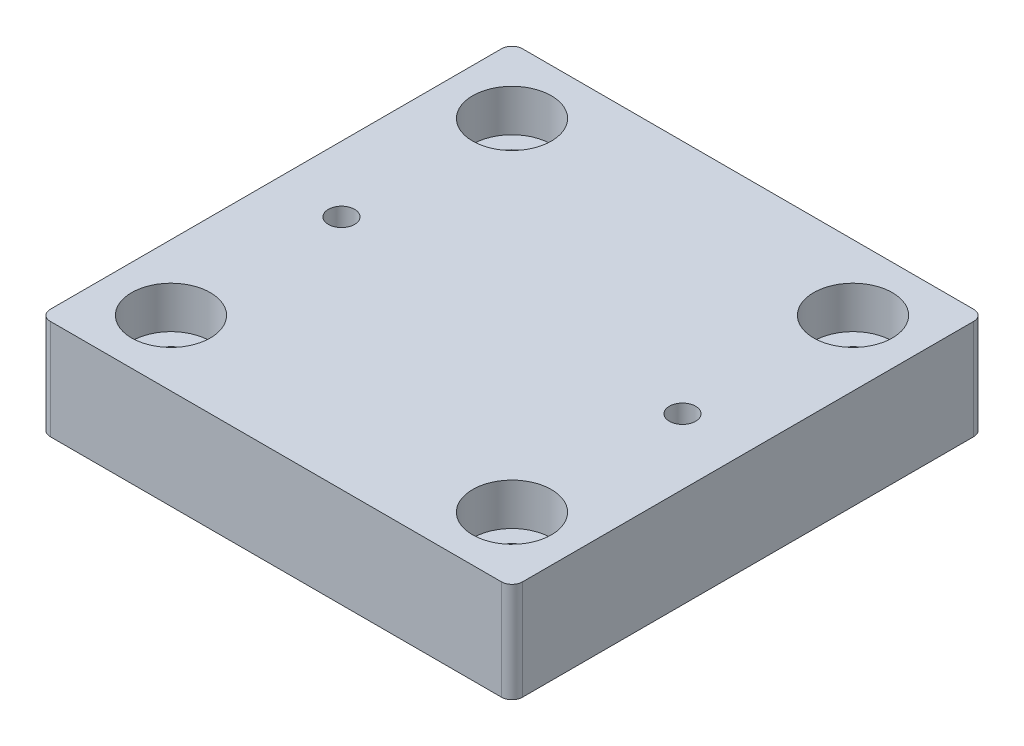
from build123d import *

# Parameters (mm, degrees)
SKETCH1_R             = 4
BOSS_EXTRUDE1_DEPTH   = 19.05
SKETCH2_R             = 7.5
CUT_EXTRUDE1_DEPTH    = 8
M6X1_0_TAPPED_HOLE1_D = 5


with BuildPart() as part:
    # Sketch1 → Boss-Extrude1 (new body)
    with BuildSketch(Plane(origin=(0, 0, 0), x_dir=(1, 0, 0), z_dir=(0, 1, 0))):
        with BuildLine():
            Line((-43, -45), (43, -45))
            ThreePointArc((43, -45), (44.414213562, -44.414213562), (45, -43))
            Line((45, -43), (45, 43))
            ThreePointArc((45, 43), (44.414213562, 44.414213562), (43, 45))
            Line((43, 45), (-43, 45))
            ThreePointArc((-43, 45), (-44.414213562, 44.414213562), (-45, 43))
            Line((-45, 43), (-45, -43))
            ThreePointArc((-45, -43), (-44.414213562, -44.414213562), (-43, -45))
        make_face()
        with Locations((-32.5, 32.5)):
            Circle(SKETCH1_R, mode=Mode.SUBTRACT)
        with Locations((32.5, 32.5)):
            Circle(SKETCH1_R, mode=Mode.SUBTRACT)
        with Locations((32.5, -32.5)):
            Circle(SKETCH1_R, mode=Mode.SUBTRACT)
        with Locations((-32.5, -32.5)):
            Circle(SKETCH1_R, mode=Mode.SUBTRACT)
    extrude(amount=BOSS_EXTRUDE1_DEPTH)

    # Sketch2 → Cut-Extrude1 (cut)
    with BuildSketch(Plane(origin=(0, 19.05, 0), x_dir=(1, 0, 0), z_dir=(0, 1, 0))):
        with Locations((-32.5, -32.5)):
            Circle(SKETCH2_R)
        with Locations((32.5, -32.5)):
            Circle(SKETCH2_R)
        with Locations((32.5, 32.5)):
            Circle(SKETCH2_R)
        with Locations((-32.5, 32.5)):
            Circle(SKETCH2_R)
    extrude(amount=-CUT_EXTRUDE1_DEPTH, mode=Mode.SUBTRACT)

    # M6x1.0 Tapped Hole1 (through all)
    with Locations(Plane(origin=(0, 19.05, 0), x_dir=(1, 0, 0), z_dir=(0, 1, 0))):
        with Locations((-32.5, 0), (32.5, 0)):
            Hole(M6X1_0_TAPPED_HOLE1_D / 2)


solid = part.part
